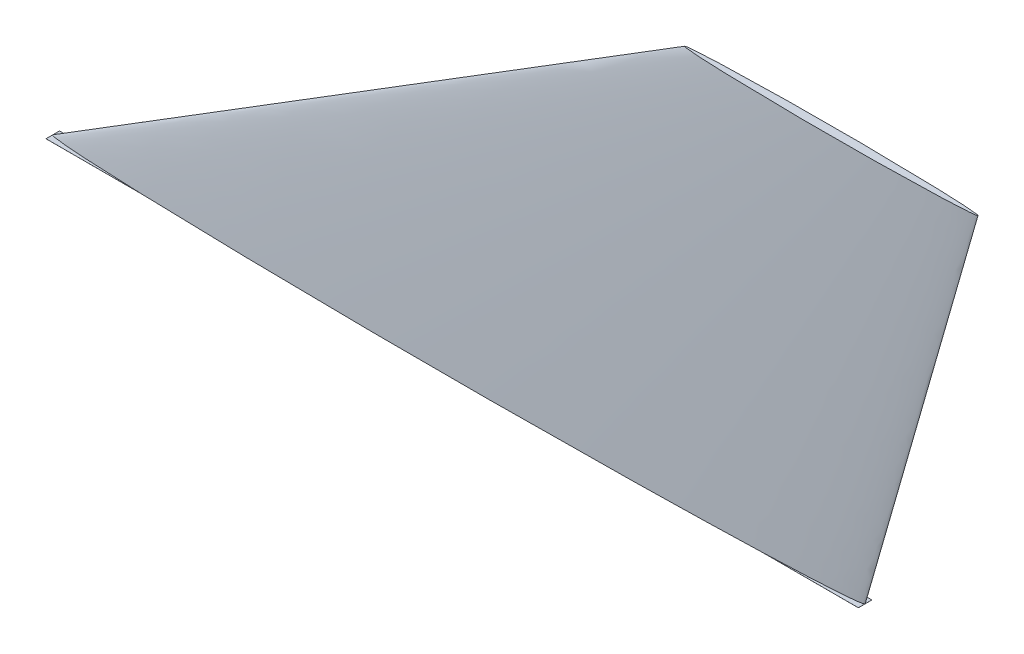
from build123d import *

# Parameters (mm, degrees)
SKETCH1_W           = 180
SKETCH1_H           = 0.01
BOSS_EXTRUDE1_DEPTH = 1.5


with BuildPart() as part:
    # Sketch1 → Boss-Extrude1 (new, symmetric)
    with BuildSketch(Plane.XY):
        with Locations((90, -0.005)):
            Rectangle(SKETCH1_W, SKETCH1_H)
    extrude(amount=BOSS_EXTRUDE1_DEPTH, both=True)

    # Sketch2 → Loft2 section 0
    with BuildSketch(Plane(origin=(0, 0, 0), x_dir=(1, 0, 0), z_dir=(0, 1, 0))):
        with BuildLine():
            add(Edge.make_bspline(
                [(180, 0), (180, 1.25), (90, 3.75), (-45, 0), (90, -3.75), (180, -1.25), (180, 0)],
                knots=[0, 0, 0, 0, 0.25, 0.5, 0.75, 1, 1, 1, 1], degree=3))
        make_face()
    # Sketch3 → Loft2 section 1
    with BuildSketch(Plane(origin=(0, 87, 0), x_dir=(1, 0, 0), z_dir=(0, 1, 0))):
        with BuildLine():
            add(Edge.make_bspline(
                [(140, 0), (140, 0.5), (172.5, 1.5), (221.25, 0), (172.5, -1.5), (140, -0.5), (140, 0)],
                knots=[0, 0, 0, 0, 0.25, 0.5, 0.75, 1, 1, 1, 1], degree=3))
        make_face()
    loft()


solid = part.part
